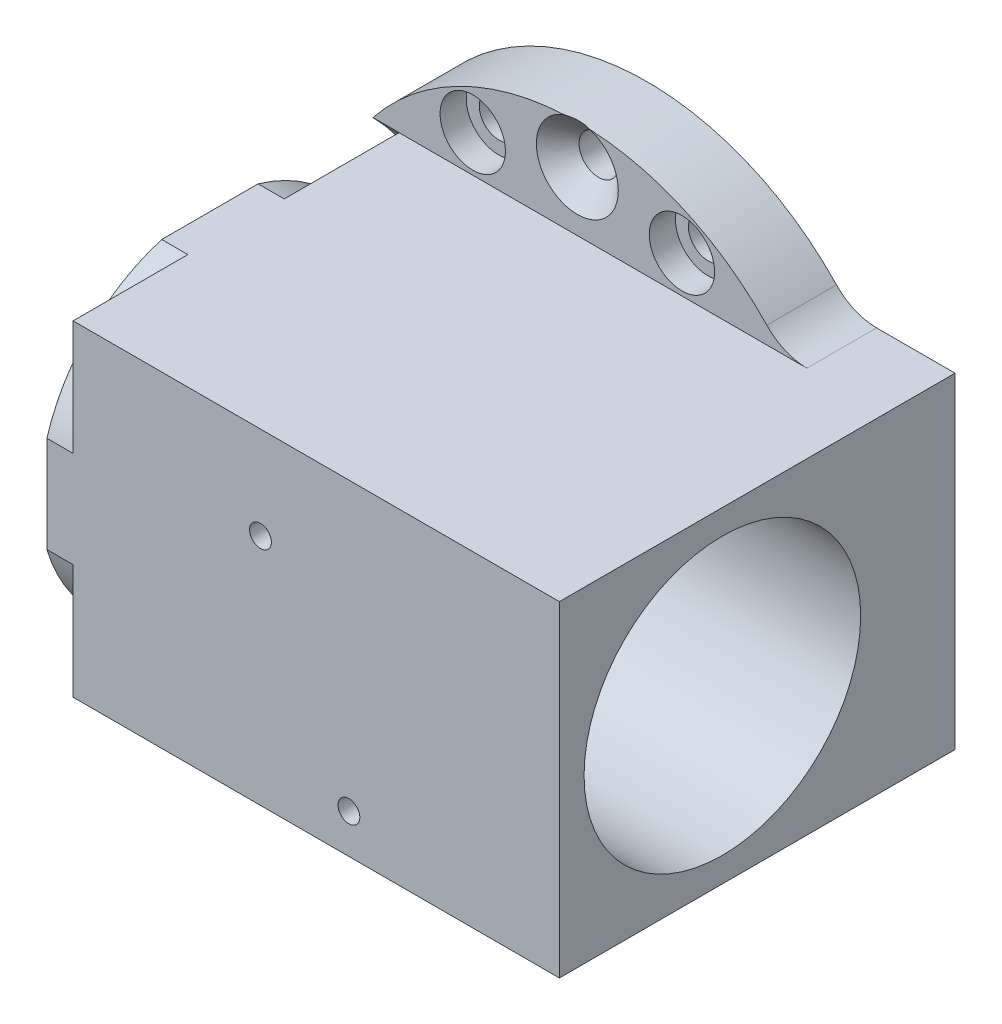
from build123d import *

# Parameters (mm, degrees)
BOSS_EXTRUDE1_DEPTH                                 = 8
CUT_EXTRUDE1_REACH                                  = 5
SKETCH4_W                                           = 55.8
SKETCH4_H                                           = 37.4
BOSS_EXTRUDE2_DEPTH                                 = 37.4
BOSS_EXTRUDE3_DEPTH                                 = 3
CUT_EXTRUDE2_DEPTH                                  = 3
CUT_EXTRUDE3_DEPTH                                  = 3
CSK_FOR_8_FLAT_HEAD_MACHINE_SCREW_100_D             = 4.5
CSK_FOR_8_FLAT_HEAD_MACHINE_SCREW_100_DEPTH         = 8
CSK_FOR_8_FLAT_HEAD_MACHINE_SCREW_100_CSINK_D       = 9.4
CSK_FOR_8_FLAT_HEAD_MACHINE_SCREW_100_CSINK_ANGLE   = 90
F_4_CLEARANCE_HOLE1_D                               = 3.3
F_4_CLEARANCE_HOLE1_DEPTH                           = 6
CBORE_FOR_8_BINDING_HEAD_MACHINE_SCREW1_D           = 4.5
CBORE_FOR_8_BINDING_HEAD_MACHINE_SCREW1_DEPTH       = 8
CBORE_FOR_8_BINDING_HEAD_MACHINE_SCREW1_CBORE_D     = 7.5
CBORE_FOR_8_BINDING_HEAD_MACHINE_SCREW1_CBORE_DEPTH = 3
FILLET1_R                                           = 6.35
M3X0_5_TAPPED_HOLE1_D                               = 2.5
M3X0_5_TAPPED_HOLE1_DEPTH                           = 4
M3X0_5_TAPPED_HOLE1_TIP                             = 0.751075774
FILLET2_R                                           = 6.35


with BuildPart() as part:
    # Sketch1 → Boss-Extrude1 (new body)
    with BuildSketch(Plane.XY.offset(8)):
        with BuildLine():
            Line((-23.45868709, 18.7), (-23.45868709, -18.7))
            ThreePointArc((-23.45868709, -18.7), (0, -30), (23.45868709, -18.7))
            Line((23.45868709, -18.7), (35.34131291, -18.7))
            Line((35.34131291, -18.7), (35.34131291, 18.7))
            Line((35.34131291, 18.7), (23.45868709, 18.7))
            ThreePointArc((23.45868709, 18.7), (0, 30), (-23.45868709, 18.7))
        make_face()
    extrude(amount=-BOSS_EXTRUDE1_DEPTH)

    # Sketch3 → Cut-Extrude1 (cut, up to next)
    with BuildSketch(Plane(origin=(-20.45868709, 0, 0), x_dir=(0, 0, -1), z_dir=(1, 0, 0)), mode=Mode.PRIVATE) as cut_extrude1_sk1:
        with BuildLine():
            Line((-8, 18.7), (-8, -18.7))
            ThreePointArc((-8, -18.7), (-0.254206384, 0), (-8, 18.7))
        make_face()
    cut_extrude1_tool1 = extrude(cut_extrude1_sk1.sketch, amount=-CUT_EXTRUDE1_REACH, mode=Mode.PRIVATE) & part.part
    add(cut_extrude1_tool1.solids().sort_by_distance((-20.458687, 0, 4.859168))[0], mode=Mode.SUBTRACT)

    # Sketch4 → Boss-Extrude2 (add)
    with BuildSketch(Plane.XY.offset(8)):
        with Locations((7.44131291, 0)):
            Rectangle(SKETCH4_W, SKETCH4_H)
    extrude(amount=BOSS_EXTRUDE2_DEPTH)

    # Sketch5 → Boss-Extrude3 (add)
    with BuildSketch(Plane.ZY.offset(20.45868709)):
        with BuildLine():
            Line((21.171890016, 18.7), (45.4, 18.7))
            Line((45.4, 18.7), (45.4, -18.7))
            Line((45.4, -18.7), (21.171890016, -18.7))
            ThreePointArc((21.171890016, -18.7), (7.2, 0), (21.171890016, 18.7))
        make_face()
    extrude(amount=BOSS_EXTRUDE3_DEPTH)

    # Sketch6 → Cut-Extrude2 (cut)
    with BuildSketch(Plane.ZY.offset(23.45868709)):
        with BuildLine():
            Line((45.4, -18.7), (45.4, -5.528109984))
            ThreePointArc((45.4, -5.528109984), (40.488582233, -13.788582233), (32.228109984, -18.7))
            Line((32.228109984, -18.7), (45.4, -18.7))
        make_face()
    extrude(amount=-CUT_EXTRUDE2_DEPTH, mode=Mode.SUBTRACT)

    # Sketch7 → Cut-Extrude3 (cut)
    with BuildSketch(Plane.ZY.offset(23.45868709)):
        with BuildLine():
            Line((45.4, 18.7), (32.228109984, 18.7))
            ThreePointArc((32.228109984, 18.7), (40.488582233, 13.788582233), (45.4, 5.528109984))
            Line((45.4, 5.528109984), (45.4, 18.7))
        make_face()
    extrude(amount=-CUT_EXTRUDE3_DEPTH, mode=Mode.SUBTRACT)

    # Sketch8 → Cut-Revolve1 (revolve, cut)
    with BuildSketch(Plane.XY.offset(26.7)):
        Polygon((-23.45868709, 15.86865), (-23.45868709, 0), (35.34131291, 0), (35.34131291, 15.86865), (9.94131291, 15.86865), (9.94131291, 13.5), (1.94131291, 13.5), (1.94131291, 15.86865), align=None)
    revolve(axis=Axis((-23.45868709, 0, 26.7), (1, 0, 0)), mode=Mode.SUBTRACT)

    # CSK for #8 Flat Head Machine Screw (100)1
    with Locations(Plane.XY.offset(8)):
        with Locations((0, 25.5), (0, -25.5)):
            CounterSinkHole(CSK_FOR_8_FLAT_HEAD_MACHINE_SCREW_100_D / 2, CSK_FOR_8_FLAT_HEAD_MACHINE_SCREW_100_CSINK_D / 2, depth=CSK_FOR_8_FLAT_HEAD_MACHINE_SCREW_100_DEPTH, counter_sink_angle=CSK_FOR_8_FLAT_HEAD_MACHINE_SCREW_100_CSINK_ANGLE)

    # #4 Clearance Hole1
    with Locations(Plane(origin=(0, -18.7, 0), x_dir=(-1, 0, 0), z_dir=(0, -1, 0))):
        with Locations((12.45868709, -39.4), (-29.44131291, -39.4), (-29.44131291, -5.9)):
            Hole(F_4_CLEARANCE_HOLE1_D / 2, depth=F_4_CLEARANCE_HOLE1_DEPTH)

    # CBORE for #8 Binding Head Machine Screw1
    with Locations(Plane.XY.offset(8)):
        with Locations((12, 22.95), (-12, 22.95), (-12, -22.95), (12, -22.95)):
            CounterBoreHole(CBORE_FOR_8_BINDING_HEAD_MACHINE_SCREW1_D / 2, CBORE_FOR_8_BINDING_HEAD_MACHINE_SCREW1_CBORE_D / 2, CBORE_FOR_8_BINDING_HEAD_MACHINE_SCREW1_CBORE_DEPTH, depth=CBORE_FOR_8_BINDING_HEAD_MACHINE_SCREW1_DEPTH)

    # Fillet1
    fillet1_edges = [part.edges().sort_by_distance(p)[0] for p in [
        (23.45868709, 18.7, 4),
    ]]
    fillet(fillet1_edges, radius=FILLET1_R)

    # M3x0.5 Tapped Hole1
    with Locations(Plane(origin=(1.04131291, 8.07366885, 45.4), x_dir=(1, 0, 0), z_dir=(0, 0, 1))):
        with Locations((0, 0), (10.150400418, -22.272670952)):
            Hole(M3X0_5_TAPPED_HOLE1_D / 2, depth=M3X0_5_TAPPED_HOLE1_DEPTH)
            with Locations((0, 0, -(M3X0_5_TAPPED_HOLE1_DEPTH + M3X0_5_TAPPED_HOLE1_TIP / 2))):  # 118° drill point
                Cone(0, M3X0_5_TAPPED_HOLE1_D / 2, M3X0_5_TAPPED_HOLE1_TIP, mode=Mode.SUBTRACT)

    # Fillet2
    fillet2_edges = [part.edges().sort_by_distance(p)[0] for p in [
        (23.45868709, -18.7, 4),
    ]]
    fillet(fillet2_edges, radius=FILLET2_R)


solid = part.part
